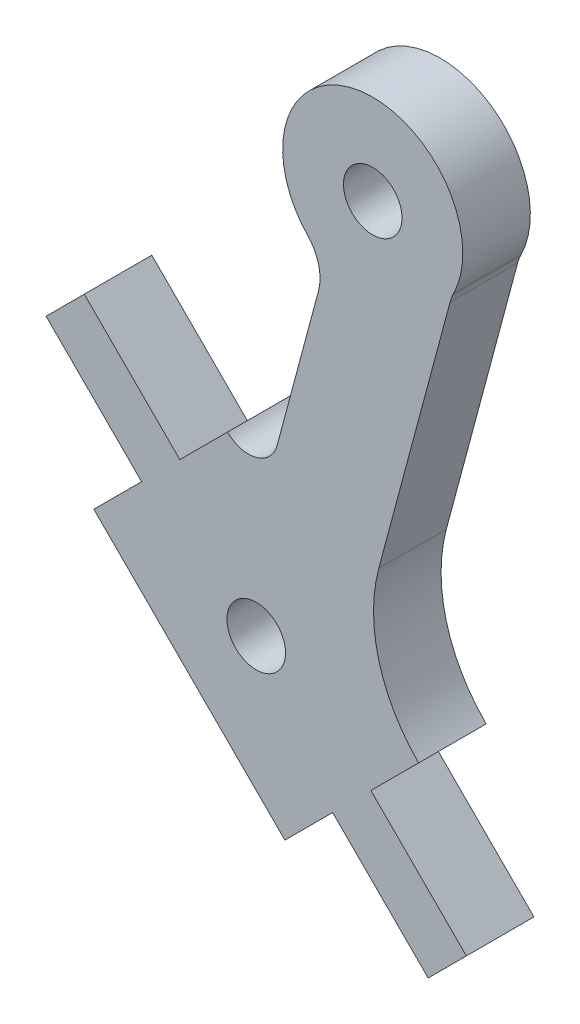
from build123d import *

# Parameters (mm, degrees)
MODEL_R             = 1.300000004
MODEL_R_2           = 1.300000002
BOSS_EXTRUDE1_DEPTH = 3


with BuildPart() as part:
    # Model → Boss-Extrude1 (new body)
    with BuildSketch(Plane.XY):
        with BuildLine():
            Line((40.053989941, 38.263739991), (41.750869933, 39.960959983))
            Line((41.750869933, 39.960959983), (45.993869928, 35.718559999))
            Line((45.993869928, 35.718559999), (48.115019916, 37.840109993))
            ThreePointArc((48.115019916, 37.840109993), (49.386777149, 37.499408798), (50.317678177, 38.430465746))
            Line((50.317678177, 38.430465746), (52.154393357, 45.286895639))
            ThreePointArc((52.154393357, 45.286895639), (52.160230302, 46.299486533), (51.669359128, 47.185161347))
            ThreePointArc((51.669359128, 47.185161347), (53.96779664, 53.902048674), (58.141990239, 48.159619035))
            ThreePointArc((58.141990239, 48.159619035), (58.061248273, 47.975250139), (57.99941682, 47.783708953))
            Line((57.99941682, 47.783708953), (54.831453076, 35.957184914))
            ThreePointArc((54.831453076, 35.957184914), (54.831683355, 32.419225016), (56.600919899, 29.355410018))
            Line((56.600919899, 29.355410018), (54.479669903, 27.233960017))
            Line((54.479669903, 27.233960017), (58.722669898, 22.991560033))
            Line((58.722669898, 22.991560033), (57.025689898, 21.294440033))
            Line((57.025689898, 21.294440033), (52.782789911, 25.536740025))
            Line((52.782789911, 25.536740025), (50.661639908, 23.415390031))
            Line((50.661639908, 23.415390031), (42.175739933, 31.899990006))
            Line((42.175739933, 31.899990006), (44.296889928, 34.02144))
            Line((44.296889928, 34.02144), (40.053989941, 38.263739991))
        make_face()
        with Locations((49.388329912, 30.627700012)):
            Circle(MODEL_R, mode=Mode.SUBTRACT)
        with Locations((54.563263872, 49.946565983)):
            Circle(MODEL_R_2, mode=Mode.SUBTRACT)
    extrude(amount=BOSS_EXTRUDE1_DEPTH)


solid = part.part
